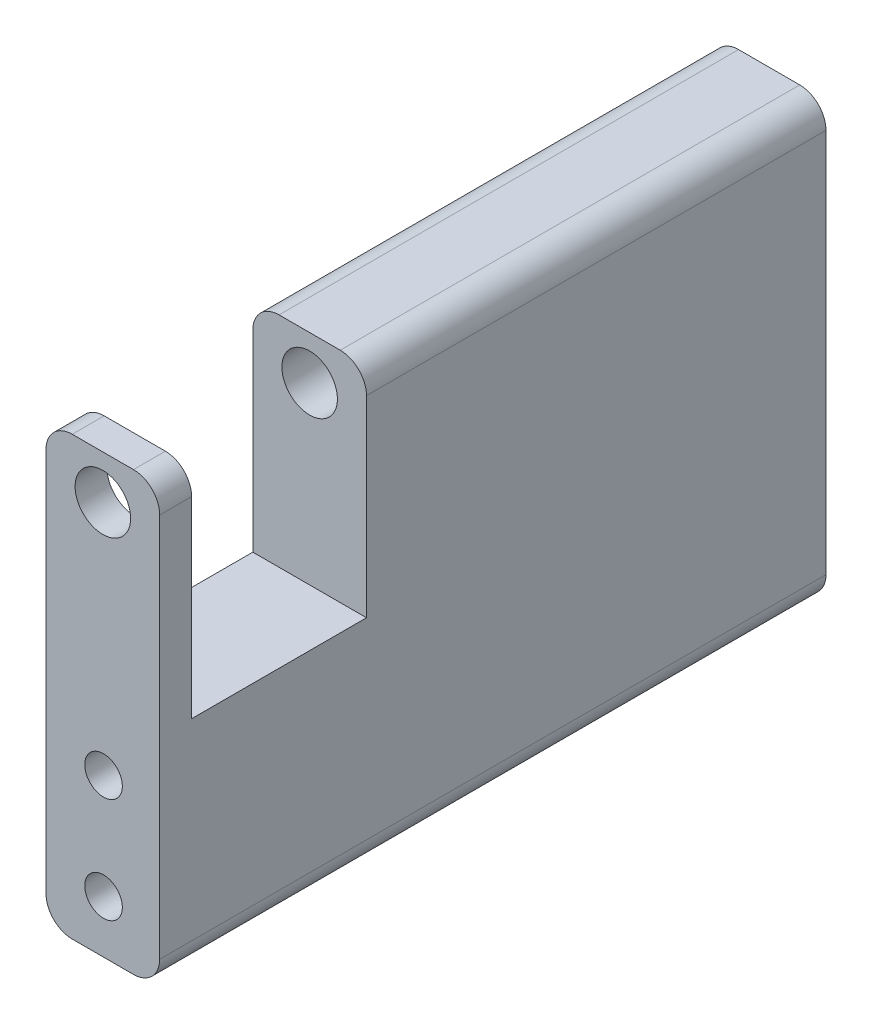
from build123d import *

# Parameters (mm, degrees)
SKETCH1_W                = 13
SKETCH1_H                = 50
SKETCH1_R                = 3.175
BOSS_EXTRUDE1_DEPTH      = 76.2
SKETCH2_W                = 13
SKETCH2_H                = 25
CUT_EXTRUDE1_DEPTH       = 10
M4_CLEARANCE_HOLE1_D     = 4.3
M4_CLEARANCE_HOLE1_DEPTH = 5
M4_CLEARANCE_HOLE1_TIP   = 1.291850331
M4_CLEARANCE_HOLE2_D     = 4.3
M4_CLEARANCE_HOLE2_DEPTH = 5
M4_CLEARANCE_HOLE2_TIP   = 1.291850331
FILLET1_R                = 3


with BuildPart() as part:
    # Sketch1 → Boss-Extrude1 (new body)
    with BuildSketch(Plane.XY):
        with Locations((6.5, 25)):
            Rectangle(SKETCH1_W, SKETCH1_H)
        with Locations((6.5, 45)):
            Circle(SKETCH1_R, mode=Mode.SUBTRACT)
    extrude(amount=BOSS_EXTRUDE1_DEPTH)

    # Sketch2 → Cut-Extrude1 (cut, symmetric)
    with BuildSketch(Plane.XY.offset(62.55)):
        with Locations((6.5, 37.5)):
            Rectangle(SKETCH2_W, SKETCH2_H)
    extrude(amount=CUT_EXTRUDE1_DEPTH, both=True, mode=Mode.SUBTRACT)

    # M4 Clearance Hole1
    with Locations(Plane(origin=(0, 0, 0), x_dir=(-1, 0, 0), z_dir=(0, 0, -1))):
        with Locations((-6.579246302, 18), (-6.579246302, 6)):
            Hole(M4_CLEARANCE_HOLE1_D / 2, depth=M4_CLEARANCE_HOLE1_DEPTH)
            with Locations((0, 0, -(M4_CLEARANCE_HOLE1_DEPTH + M4_CLEARANCE_HOLE1_TIP / 2))):  # 118° drill point
                Cone(0, M4_CLEARANCE_HOLE1_D / 2, M4_CLEARANCE_HOLE1_TIP, mode=Mode.SUBTRACT)

    # M4 Clearance Hole2
    with Locations(Plane.XY.offset(76.2)):
        with Locations((6.579246302, 18), (6.579246302, 6)):
            Hole(M4_CLEARANCE_HOLE2_D / 2, depth=M4_CLEARANCE_HOLE2_DEPTH)
            with Locations((0, 0, -(M4_CLEARANCE_HOLE2_DEPTH + M4_CLEARANCE_HOLE2_TIP / 2))):  # 118° drill point
                Cone(0, M4_CLEARANCE_HOLE2_D / 2, M4_CLEARANCE_HOLE2_TIP, mode=Mode.SUBTRACT)

    # Fillet1
    fillet1_edges = [part.edges().sort_by_distance(p)[0] for p in [
        (0, 50, 26.275),
        (13, 50, 26.275),
        (0, 50, 74.375),
        (13, 50, 74.375),
        (13, 0, 38.1),
        (0, 0, 38.1),
    ]]
    fillet(fillet1_edges, radius=FILLET1_R)


solid = part.part
